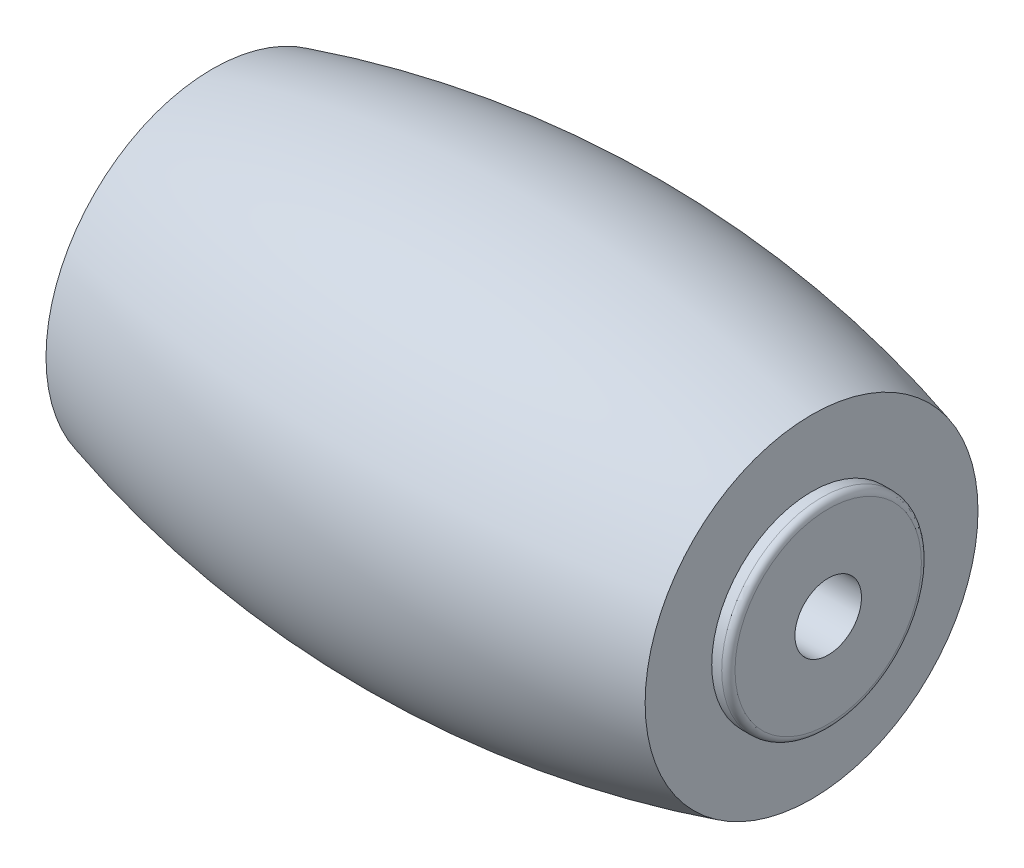
from build123d import *

# Parameters (mm, degrees)
SKETCH3_R           = 3
BOSS_EXTRUDE1_DEPTH = 0.5
SKETCH4_R           = 1
CUT_EXTRUDE2_DEPTH  = 20
FILLET1_R           = 0.2
SCALE_1_SCALE       = 0.894736842


with BuildPart() as part:
    # Sketch1 → Revolve1 (revolve)
    with BuildSketch(Plane(origin=(0, 0, 0), x_dir=(1, 0, 0), z_dir=(0, 1, 0))):
        with BuildLine():
            Line((0, 0), (-9, 0))
            Line((-9, 0), (-9, 5))
            ThreePointArc((-9, 5), (0, 6.249672879), (9, 5))
            Line((9, 5), (9, 0))
            Line((9, 0), (0, 0))
        make_face()
    revolve(axis=Axis((0, 0, 0), (-1, 0, 0)))

    # Sketch3 → Boss-Extrude1 (add)
    with BuildSketch(Plane(origin=(9, 0, 0), x_dir=(0, 0, -1), z_dir=(1, 0, 0))):
        Circle(SKETCH3_R)
    boss_extrude1 = extrude(amount=BOSS_EXTRUDE1_DEPTH)

    # Mirror1: Boss-Extrude1 across plane
    add(boss_extrude1.mirror(Plane(origin=(0, 0, 0), x_dir=(0, 0, 1), z_dir=(1, 0, 0))))

    # Sketch4 → Cut-Extrude2 (cut, through all)
    with BuildSketch(Plane.ZY.offset(9.5)):
        Circle(SKETCH4_R)
    extrude(amount=-CUT_EXTRUDE2_DEPTH, mode=Mode.SUBTRACT)

    # Fillet1
    fillet1_edges = [part.edges().sort_by_distance(p)[0] for p in [
        (9.5, 0, 3),
        (-9.5, 0, 3),
    ]]
    fillet(fillet1_edges, radius=FILLET1_R)


with BuildPart() as part_1:
    # ｽｹｰﾙ1: scaled about (0, 0, 0)
    add(part.part.scale(SCALE_1_SCALE))


solid = part_1.part
